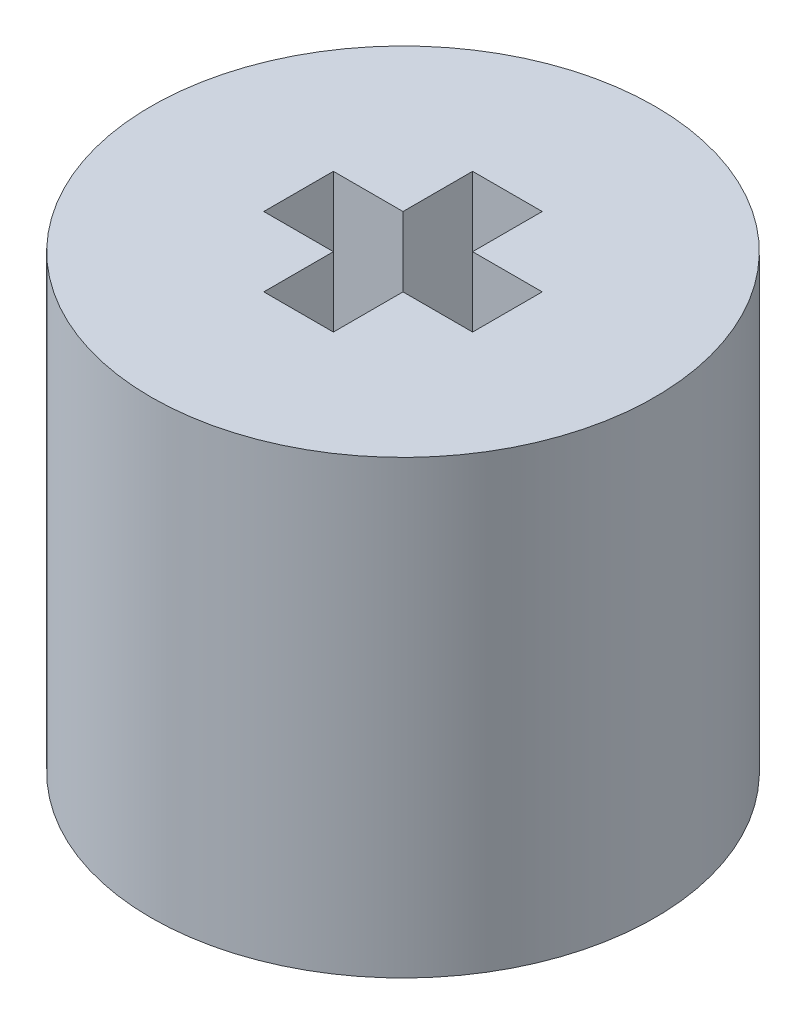
from build123d import *

# Parameters (mm, degrees)
SKETCH1_R           = 7.239
SKETCH1_W           = 3.175
SKETCH1_H           = 3.175
BOSS_EXTRUDE1_DEPTH = 6.35
SKETCH2_R           = 7.239
SKETCH2_W           = 3.175
SKETCH2_H           = 3.175
BOSS_EXTRUDE2_DEPTH = 0.254
SKETCH3_R           = 7.239
BOSS_EXTRUDE3_DEPTH = 6.35


with BuildPart() as part:
    # Sketch1 → Boss-Extrude1 (new body)
    with BuildSketch(Plane(origin=(0, 0, 0), x_dir=(1, 0, 0), z_dir=(0, 1, 0))):
        Circle(SKETCH1_R)
        Rectangle(SKETCH1_W, SKETCH1_H, mode=Mode.SUBTRACT)
    extrude(amount=BOSS_EXTRUDE1_DEPTH)

    # Sketch2 → Boss-Extrude2 (add)
    with BuildSketch(Plane(origin=(0, 6.35, 0), x_dir=(1, 0, 0), z_dir=(0, 1, 0))):
        Circle(SKETCH2_R)
        Rectangle(SKETCH2_W, SKETCH2_H, mode=Mode.SUBTRACT)
        Rectangle(SKETCH2_W, SKETCH2_H)
    extrude(amount=BOSS_EXTRUDE2_DEPTH)

    # Sketch3 → Boss-Extrude3 (add)
    with BuildSketch(Plane(origin=(0, 6.604, 0), x_dir=(1, 0, 0), z_dir=(0, 1, 0))):
        Circle(SKETCH3_R)
        Polygon((-1, -1), (-3, -1), (-3, 1), (-1, 1), (-1, 3), (1, 3), (1, 1), (3, 1), (3, -1), (1, -1), (1, -3), (-1, -3), align=None, mode=Mode.SUBTRACT)
    extrude(amount=BOSS_EXTRUDE3_DEPTH)


solid = part.part
